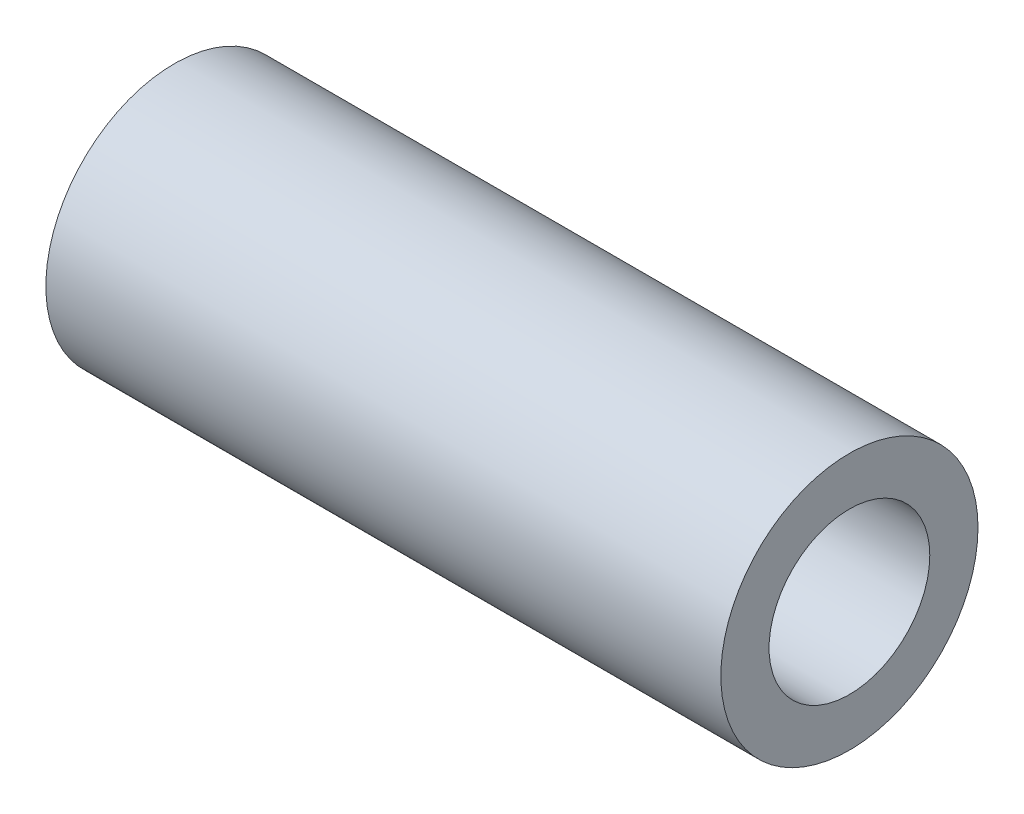
from build123d import *

# Parameters (mm, degrees)
SKETCH1_R           = 4
SKETCH1_R_2         = 2.5
BOSS_EXTRUDE1_DEPTH = 10.5


with BuildPart() as part:
    # Sketch1 → Boss-Extrude1 (new body, symmetric)
    with BuildSketch(Plane(origin=(0, 0, 0), x_dir=(0, 0, -1), z_dir=(1, 0, 0))):
        Circle(SKETCH1_R)
        Circle(SKETCH1_R_2, mode=Mode.SUBTRACT)
    extrude(amount=BOSS_EXTRUDE1_DEPTH, both=True)


solid = part.part
